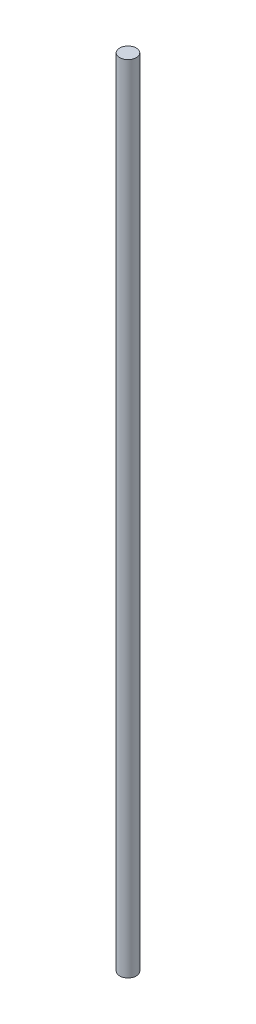
from build123d import *

# Parameters (mm, degrees)
SKETCH1_R           = 5
BOSS_EXTRUDE1_DEPTH = 477


with BuildPart() as part:
    # Sketch1 → Boss-Extrude1 (new body)
    with BuildSketch(Plane(origin=(0, 0, 0), x_dir=(1, 0, 0), z_dir=(0, 1, 0))):
        with Locations(Location((0, 0, 0), (0, 0, 270))):  # turned: the seam where the file's is
            Circle(SKETCH1_R)
    extrude(amount=BOSS_EXTRUDE1_DEPTH)


solid = part.part
